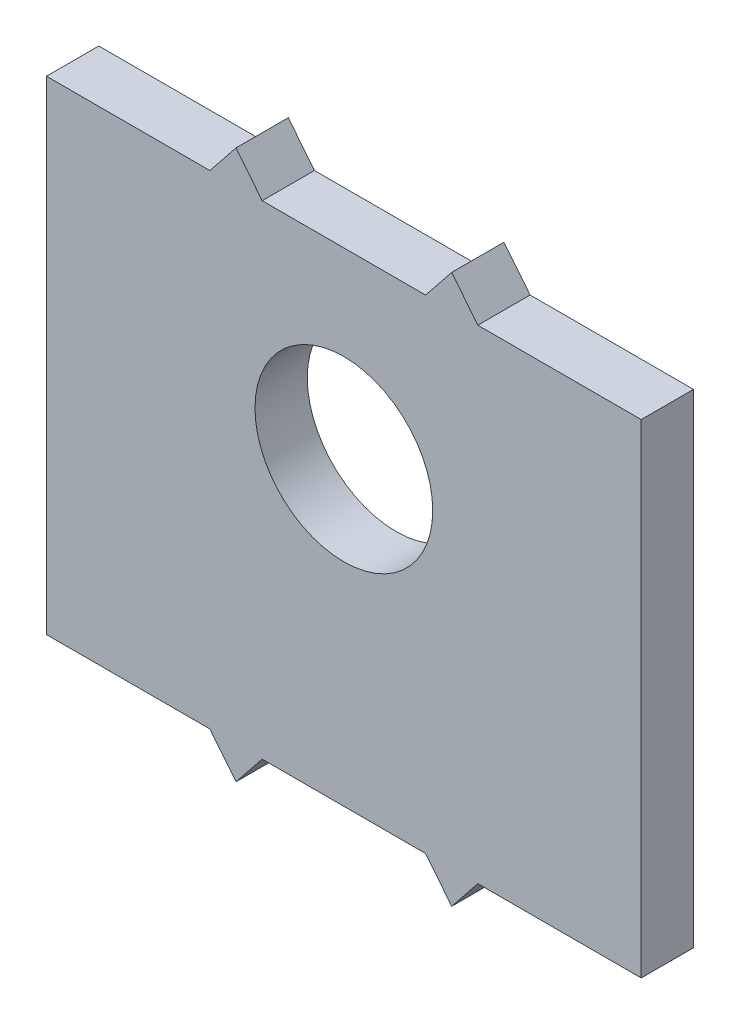
from build123d import *

# Parameters (mm, degrees)
SKETCH1_W        = 45.5
SKETCH1_H        = 37
BASIS_DEPTH      = 4
SKETCH2_R        = 6.8
CAMERA_GAT_DEPTH = 4


with BuildPart() as part:
    # Sketch1 → Basis (new body)
    with BuildSketch(Plane.XY):
        with Locations((22.75, 18.5)):
            Rectangle(SKETCH1_W, SKETCH1_H)
        Polygon((14.5, 39.5), (12.5, 37), (16.5, 37), align=None)
        Polygon((31, 39.5), (29, 37), (33, 37), align=None)
        Polygon((16.5, 0), (12.5, 0), (14.5, -2.5), align=None)
        Polygon((33, 0), (29, 0), (31, -2.5), align=None)
    extrude(amount=BASIS_DEPTH)

    # Sketch2 → Camera gat (cut)
    with BuildSketch(Plane.XY.offset(4)):
        with Locations((22.75, 23)):
            Circle(SKETCH2_R)
    extrude(amount=-CAMERA_GAT_DEPTH, mode=Mode.SUBTRACT)


solid = part.part
